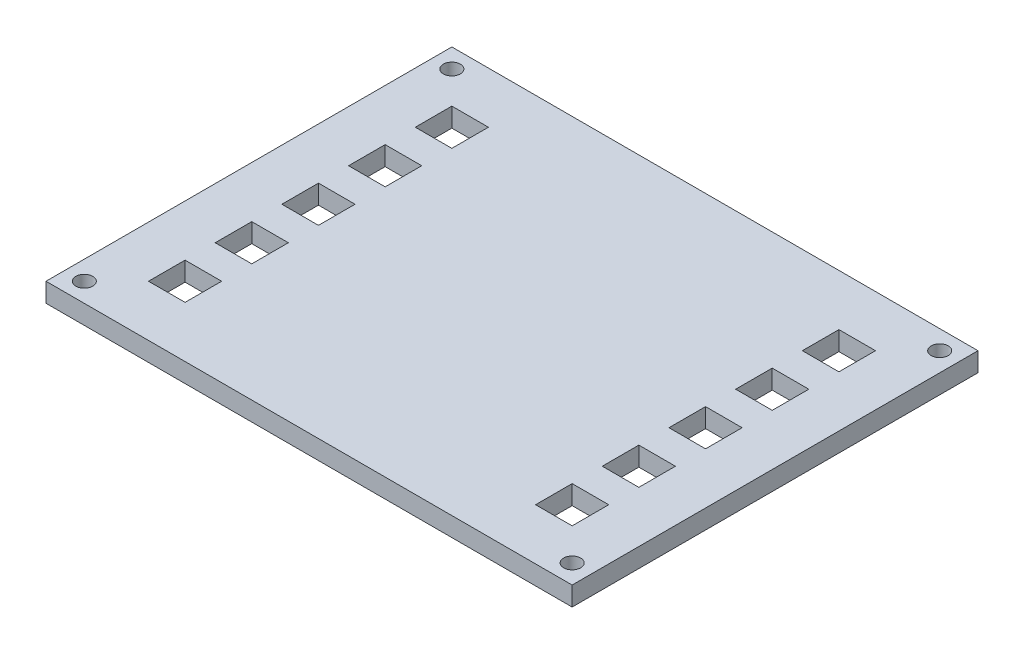
from build123d import *

# Parameters (mm, degrees)
SKETCH1_W           = 100.17
SKETCH1_H           = 80.17
BOSS_EXTRUDE1_DEPTH = 3.175
SKETCH2_W           = 6.08
SKETCH2_H           = 6.08
CUT_EXTRUDE2_DEPTH  = 4.175
LPATTERN1_COUNT     = 5
LPATTERN1_PITCH     = 11.0875
SKETCH5_W           = 107.47
SKETCH5_H           = 87.47
SKETCH5_W_2         = 87.47
SKETCH5_H_2         = 67.47
CUT_EXTRUDE4_DEPTH  = 10
SKETCH6_R           = 1.415
CUT_EXTRUDE5_DEPTH  = 10


with BuildPart() as part:
    # Sketch1 → Boss-Extrude1 (new body)
    with BuildSketch(Plane(origin=(0, 0, 0), x_dir=(1, 0, 0), z_dir=(0, 1, 0))):
        Rectangle(SKETCH1_W, SKETCH1_H)
    extrude(amount=BOSS_EXTRUDE1_DEPTH)

    # Sketch2 → Cut-Extrude2 (cut, through all)
    with BuildSketch(Plane(origin=(0, 3.175, 0), x_dir=(1, 0, 0), z_dir=(0, 1, 0))):
        with Locations((-32.175, 22.175)):
            Rectangle(SKETCH2_W, SKETCH2_H)
        with Locations((32.175, 22.175)):
            Rectangle(SKETCH2_W, SKETCH2_H)
    cut_extrude2 = extrude(amount=-CUT_EXTRUDE2_DEPTH, mode=Mode.SUBTRACT)

    # LPattern1: Cut-Extrude2 ×5
    with Locations(*[(0, 0, i * LPATTERN1_PITCH) for i in range(1, LPATTERN1_COUNT)]):
        add(cut_extrude2, mode=Mode.SUBTRACT)

    # Sketch5 → Cut-Extrude4 (cut)
    with BuildSketch(Plane(origin=(0, 3.175, 0), x_dir=(1, 0, 0), z_dir=(0, 1, 0))):
        Rectangle(SKETCH5_W, SKETCH5_H)
        Rectangle(SKETCH5_W_2, SKETCH5_H_2, mode=Mode.SUBTRACT)
    extrude(amount=-CUT_EXTRUDE4_DEPTH, mode=Mode.SUBTRACT)

    # Sketch6 → Cut-Extrude5 (cut)
    with BuildSketch(Plane(origin=(0, 3.175, 0), x_dir=(1, 0, 0), z_dir=(0, 1, 0))):
        with Locations((-40.553019485, 30.553019485)):
            Circle(SKETCH6_R)
        with Locations((-40.553019485, -30.553019485)):
            Circle(SKETCH6_R)
        with Locations((40.553019485, -30.553019485)):
            Circle(SKETCH6_R)
        with Locations((40.553019485, 30.553019485)):
            Circle(SKETCH6_R)
    extrude(amount=-CUT_EXTRUDE5_DEPTH, mode=Mode.SUBTRACT)


solid = part.part
